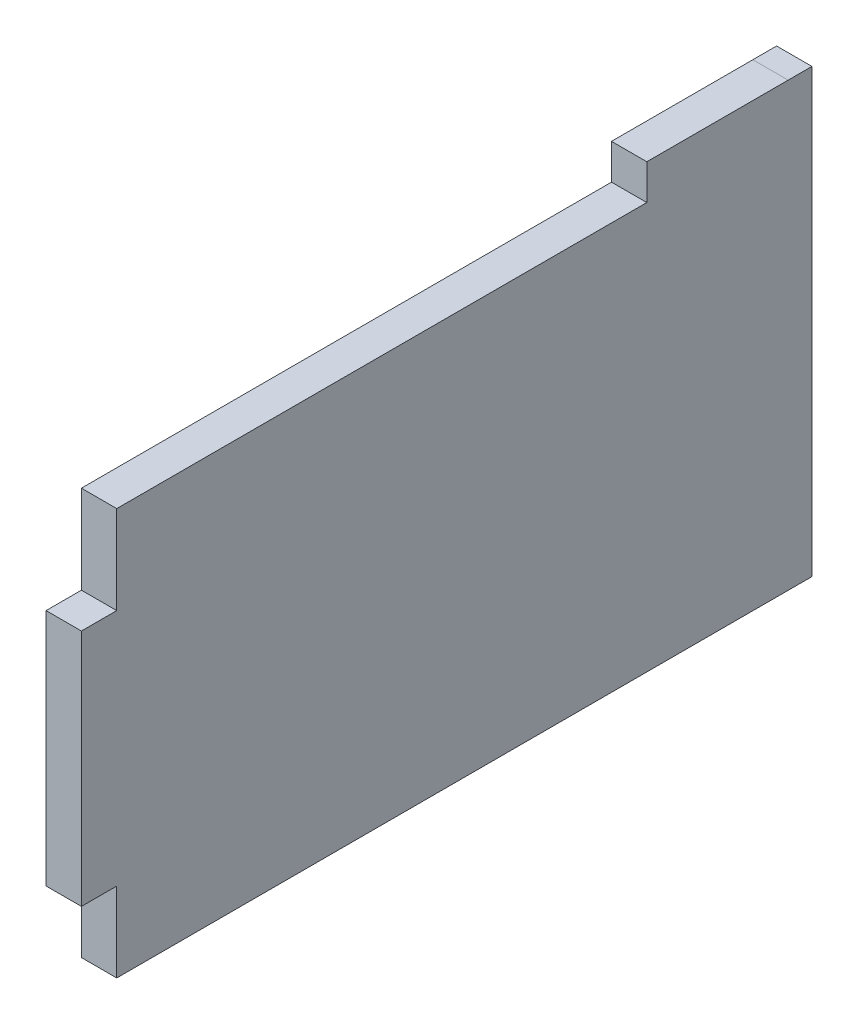
from build123d import *

# Parameters (mm, degrees)
BOSS_EXTRUDE1_DEPTH     = 4
CUT_EXTRUDE1_DEPTH      = 10
CUT_EXTRUDE1_DEPTH_BACK = 10
SKETCH4_W               = 4
SKETCH4_H               = 50.01485274
BOSS_EXTRUDE3_DEPTH     = 2.69


with BuildPart() as part:
    # Sketch2 → Boss-Extrude1 (new body)
    with BuildSketch(Plane(origin=(0, 0, 0), x_dir=(0, 0, -1), z_dir=(1, 0, 0))):
        Polygon((61, 4), (101, 4), (101, 0), (161.781661072, 0), (161.781661072, -10), (165.781661072, -10), (165.781661072, -37), (161.781661072, -37), (161.781661072, -46.015400021), (1, -46.015400021), (1, -37), (-3, -37), (-3, -10), (1, -10), (1, 0), (61, 0), align=None)
    extrude(amount=BOSS_EXTRUDE1_DEPTH)

    # Sketch3 → Cut-Extrude1 (cut, two sides: drawn at the far end of the back side and taken through both)
    with BuildSketch(Plane(origin=(0, 0, 0), x_dir=(0, 0, -1), z_dir=(1, 0, 0)).offset(-CUT_EXTRUDE1_DEPTH_BACK)):
        Polygon((77, 4.594080923), (187.139354616, 4.594080923), (187.139354616, -56.777475016), (77, -56.777475016), (77, -46.986682045), align=None)
    extrude(amount=CUT_EXTRUDE1_DEPTH + CUT_EXTRUDE1_DEPTH_BACK, mode=Mode.SUBTRACT)

    # Sketch4 → Boss-Extrude3 (add)
    with BuildSketch(Plane(origin=(0, 0, -77), x_dir=(-1, 0, 0), z_dir=(0, 0, -1))):
        with Locations((-2, -21.007973651)):
            Rectangle(SKETCH4_W, SKETCH4_H)
    extrude(amount=BOSS_EXTRUDE3_DEPTH)


solid = part.part
